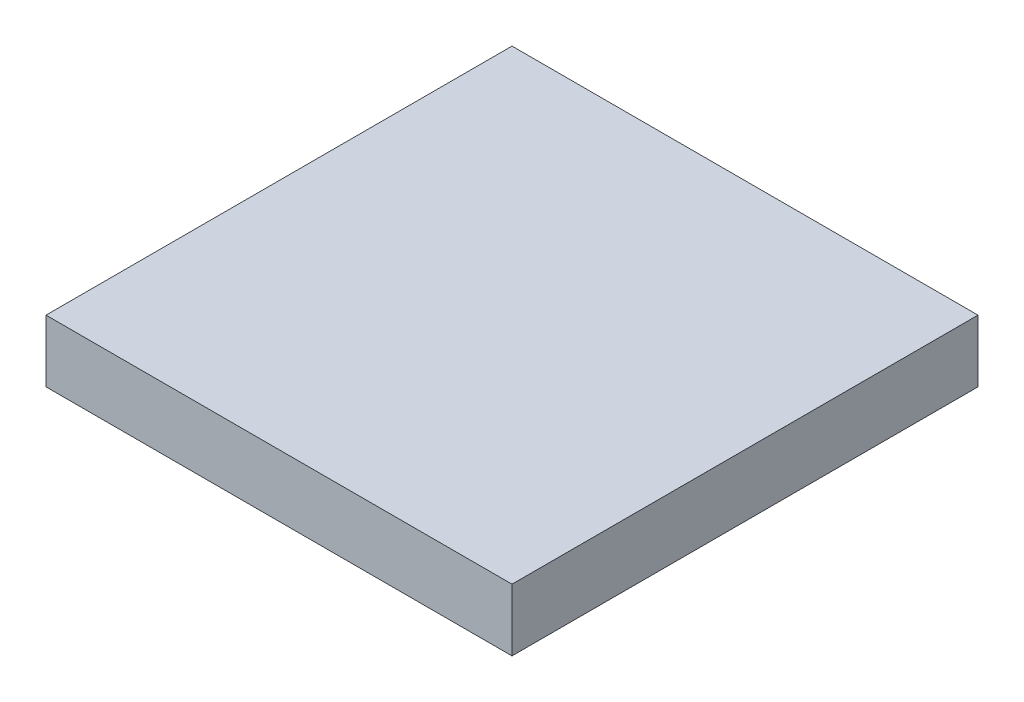
from build123d import *

# Parameters (mm, degrees)
SKETCH1_W           = 15
SKETCH1_H           = 15
BOSS_EXTRUDE1_DEPTH = 2


with BuildPart() as part:
    # Sketch1 → Boss-Extrude1 (new body)
    with BuildSketch(Plane(origin=(0, 0, 0), x_dir=(1, 0, 0), z_dir=(0, 1, 0))):
        Rectangle(SKETCH1_W, SKETCH1_H)
    extrude(amount=BOSS_EXTRUDE1_DEPTH)


solid = part.part
